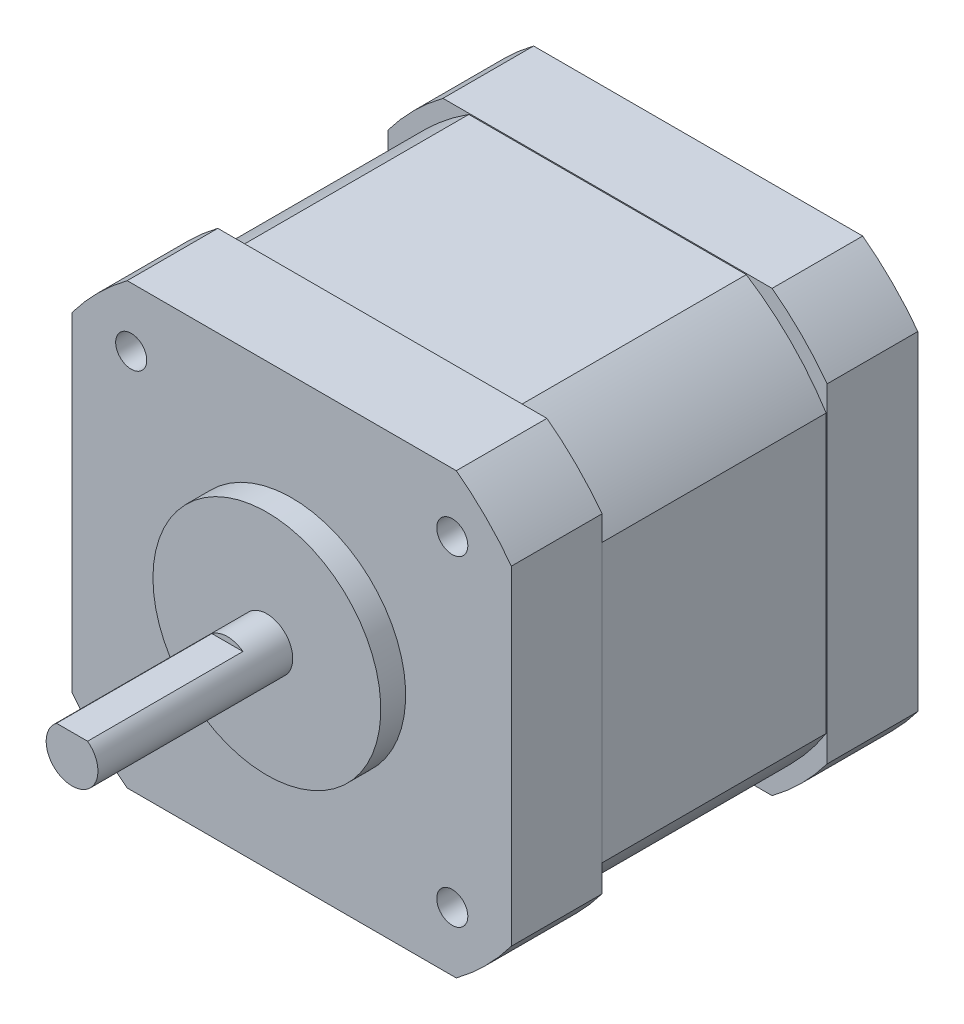
from build123d import *

# Parameters (mm, degrees)
SKETCH1_R                       = 2.5
BOSS_EXTRUDE1_DEPTH             = 21.21
SKETCH2_R                       = 11
BOSS_EXTRUDE2_DEPTH             = 2.4
SKETCH3_W                       = 42.418
SKETCH3_H                       = 42.418
BOSS_EXTRUDE3_DEPTH             = 39.24
CUT_EXTRUDE1_DEPTH              = 61.45
M3X0_5_TAPPED_HOLE1_D           = 2.5
M3X0_5_TAPPED_HOLE1_DEPTH       = 7.5
M3X0_5_TAPPED_HOLE1_CBORE_D     = 3
M3X0_5_TAPPED_HOLE1_CBORE_DEPTH = 6
M3X0_5_TAPPED_HOLE1_TIP         = 0.751075774
CUT_EXTRUDE2_DEPTH              = 15
CUT_EXTRUDE3_DEPTH              = 10.87


with BuildPart() as part:
    # Sketch1 → Boss-Extrude1 (new body)
    with BuildSketch(Plane.XY):
        Circle(SKETCH1_R)
    extrude(amount=BOSS_EXTRUDE1_DEPTH)

    # Sketch2 → Boss-Extrude2 (add)
    with BuildSketch(Plane(origin=(0, 0, 0), x_dir=(-1, 0, 0), z_dir=(0, 0, -1))):
        Circle(SKETCH2_R)
    extrude(amount=-BOSS_EXTRUDE2_DEPTH)

    # Sketch3 → Boss-Extrude3 (add)
    with BuildSketch(Plane(origin=(0, 0, 0), x_dir=(-1, 0, 0), z_dir=(0, 0, -1))):
        Rectangle(SKETCH3_W, SKETCH3_H)
    extrude(amount=BOSS_EXTRUDE3_DEPTH)

    # Sketch4 → Cut-Extrude1 (cut, through all)
    with BuildSketch(Plane(origin=(0, 0, -39.24), x_dir=(-1, 0, 0), z_dir=(0, 0, -1))):
        with BuildLine():
            Line((-21.209, -15.887992919), (-21.209, -21.209))
            Line((-21.209, -21.209), (-15.887992919, -21.209))
            ThreePointArc((-15.887992919, -21.209), (-18.738329701, -18.738329701), (-21.209, -15.887992919))
        make_face()
        with BuildLine():
            Line((15.887992919, -21.209), (21.209, -21.209))
            Line((21.209, -21.209), (21.209, -15.887992919))
            ThreePointArc((21.209, -15.887992919), (18.738329701, -18.738329701), (15.887992919, -21.209))
        make_face()
        with BuildLine():
            Line((21.209, 15.887992919), (21.209, 21.209))
            Line((21.209, 21.209), (15.887992919, 21.209))
            ThreePointArc((15.887992919, 21.209), (18.738329701, 18.738329701), (21.209, 15.887992919))
        make_face()
        with BuildLine():
            Line((-15.887992919, 21.209), (-21.209, 21.209))
            Line((-21.209, 21.209), (-21.209, 15.887992919))
            ThreePointArc((-21.209, 15.887992919), (-18.738329701, 18.738329701), (-15.887992919, 21.209))
        make_face()
    extrude(amount=-CUT_EXTRUDE1_DEPTH, mode=Mode.SUBTRACT)

    # M3x0.5 Tapped Hole1
    with Locations(Plane.XY):
        with Locations((-15.5, 15.5), (-15.5, -15.5), (15.5, -15.5), (15.5, 15.5)):
            CounterBoreHole(M3X0_5_TAPPED_HOLE1_D / 2, M3X0_5_TAPPED_HOLE1_CBORE_D / 2, M3X0_5_TAPPED_HOLE1_CBORE_DEPTH, depth=M3X0_5_TAPPED_HOLE1_DEPTH)
            with Locations((0, 0, -(M3X0_5_TAPPED_HOLE1_DEPTH + M3X0_5_TAPPED_HOLE1_TIP / 2))):  # 118° drill point
                Cone(0, M3X0_5_TAPPED_HOLE1_D / 2, M3X0_5_TAPPED_HOLE1_TIP, mode=Mode.SUBTRACT)

    # Sketch7 → Cut-Extrude2 (cut)
    with BuildSketch(Plane.XY.offset(21.21)):
        with BuildLine():
            Line((-1.5, 2), (1.5, 2))
            ThreePointArc((1.5, 2), (0, 2.5), (-1.5, 2))
        make_face()
    extrude(amount=-CUT_EXTRUDE2_DEPTH, mode=Mode.SUBTRACT)

    # Sketch8 → Cut-Extrude3 (cut, symmetric)
    with BuildSketch(Plane.XY.offset(-19.62)):
        with BuildLine():
            Line((15.887992919, 21.209), (-15.887992919, 21.209))
            ThreePointArc((-15.887992919, 21.209), (-18.738329701, 18.738329701), (-21.209, 15.887992919))
            Line((-21.209, 15.887992919), (-21.209, -15.887992919))
            ThreePointArc((-21.209, -15.887992919), (-18.738329701, -18.738329701), (-15.887992919, -21.209))
            Line((-15.887992919, -21.209), (15.887992919, -21.209))
            ThreePointArc((15.887992919, -21.209), (18.738329701, -18.738329701), (21.209, -15.887992919))
            Line((21.209, -15.887992919), (21.209, 15.887992919))
            ThreePointArc((21.209, 15.887992919), (18.738329701, 18.738329701), (15.887992919, 21.209))
        make_face()
        with BuildLine():
            Line((-13.394406258, 21.109), (13.394406258, 21.109))
            ThreePointArc((13.394406258, 21.109), (17.67766953, 17.67766953), (21.109, 13.394406258))
            Line((21.109, 13.394406258), (21.109, -13.394406258))
            ThreePointArc((21.109, -13.394406258), (17.67766953, -17.67766953), (13.394406258, -21.109))
            Line((13.394406258, -21.109), (-13.394406258, -21.109))
            ThreePointArc((-13.394406258, -21.109), (-17.67766953, -17.67766953), (-21.109, -13.394406258))
            Line((-21.109, -13.394406258), (-21.109, 13.394406258))
            ThreePointArc((-21.109, 13.394406258), (-17.67766953, 17.67766953), (-13.394406258, 21.109))
        make_face(mode=Mode.SUBTRACT)
    extrude(amount=CUT_EXTRUDE3_DEPTH, both=True, mode=Mode.SUBTRACT)


solid = part.part
